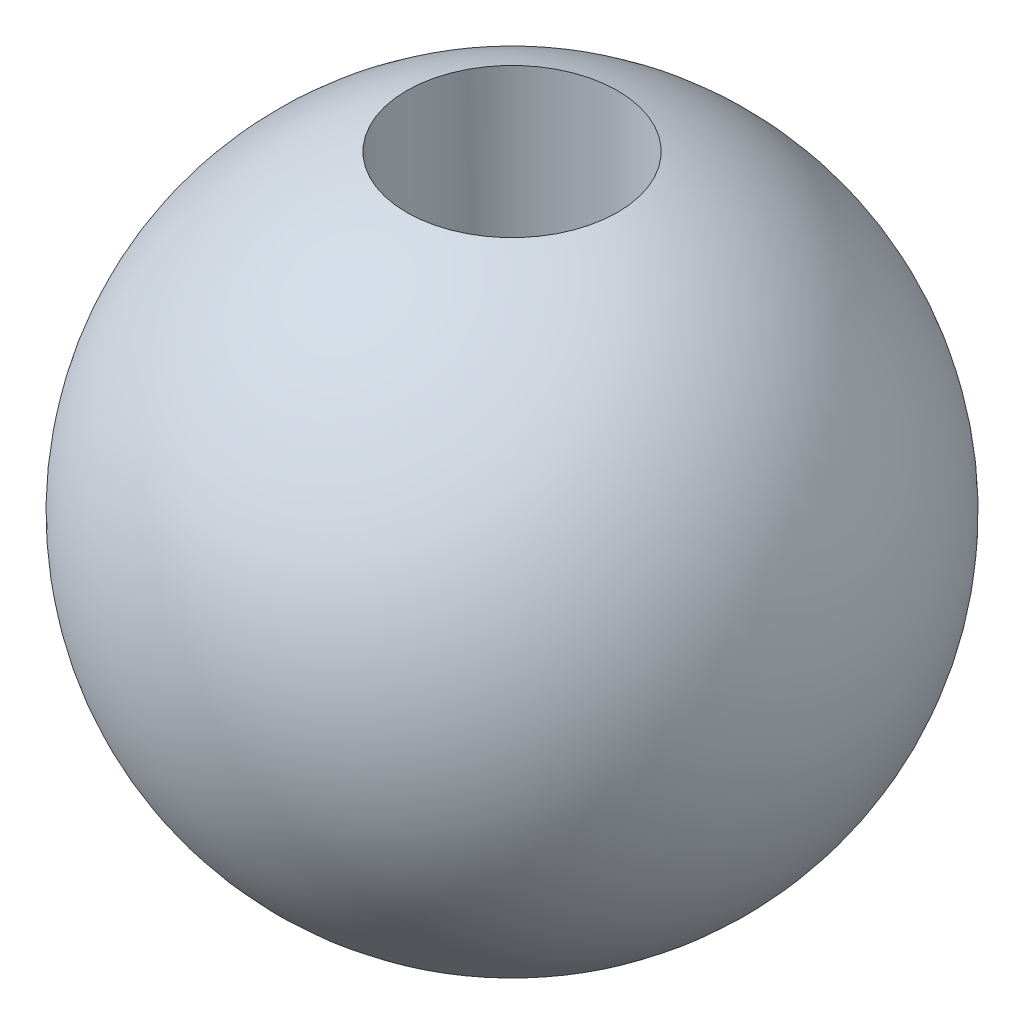
from build123d import *

# Parameters (mm, degrees)
SKIZZE3_R                       = 4
SCHNITT_LINEAR_AUSTRAGEN1_DEPTH = 20
SCHNITT_LINEAR_START            = -2
SKIZZE6_R                       = 5.15
SCHNITT_LINEAR_AUSTRAGEN2_DEPTH = 20.277922831


with BuildPart() as part:
    # Skizze1 → Rotation1 (revolve)
    with BuildSketch(Plane.XY):
        with BuildLine():
            Line((0, 12.5), (0, -12.5))
            ThreePointArc((0, -12.5), (-12.5, 0), (0, 12.5))
        make_face()
    revolve(axis=Axis((0, 27.42628623, 0), (0, -1, 0)))

    # Skizze3 → Schnitt-Linear austragen1 (cut, symmetric)
    with BuildSketch(Plane(origin=(0, 0, 0), x_dir=(1, 0, 0), z_dir=(0, 1, 0))):
        Circle(SKIZZE3_R)
    extrude(amount=SCHNITT_LINEAR_AUSTRAGEN1_DEPTH, both=True, mode=Mode.SUBTRACT)

    # Skizze5 → Rotation2 (revolve)
    with BuildSketch(Plane(origin=(0, 0, 0), x_dir=(0, 0, -1), z_dir=(1, 0, 0))):
        Polygon((-2.15, 0), (-2.15, 2), (-5, 3.712452764), (-5, 0), align=None)
    rotation2 = revolve(axis=Axis((0, 0, 0), (0, 1, 0)))

    # Spiegeln1: Rotation2 across plane
    add(rotation2.mirror(Plane.ZX))

    # Skizze6 → Schnitt-Linear austragen2 (cut, through all)
    with BuildSketch(Plane(origin=(0, 0, 0), x_dir=(1, 0, 0), z_dir=(0, 1, 0)).offset(SCHNITT_LINEAR_START)):
        Circle(SKIZZE6_R)
    extrude(amount=-SCHNITT_LINEAR_AUSTRAGEN2_DEPTH, mode=Mode.SUBTRACT)


solid = part.part
